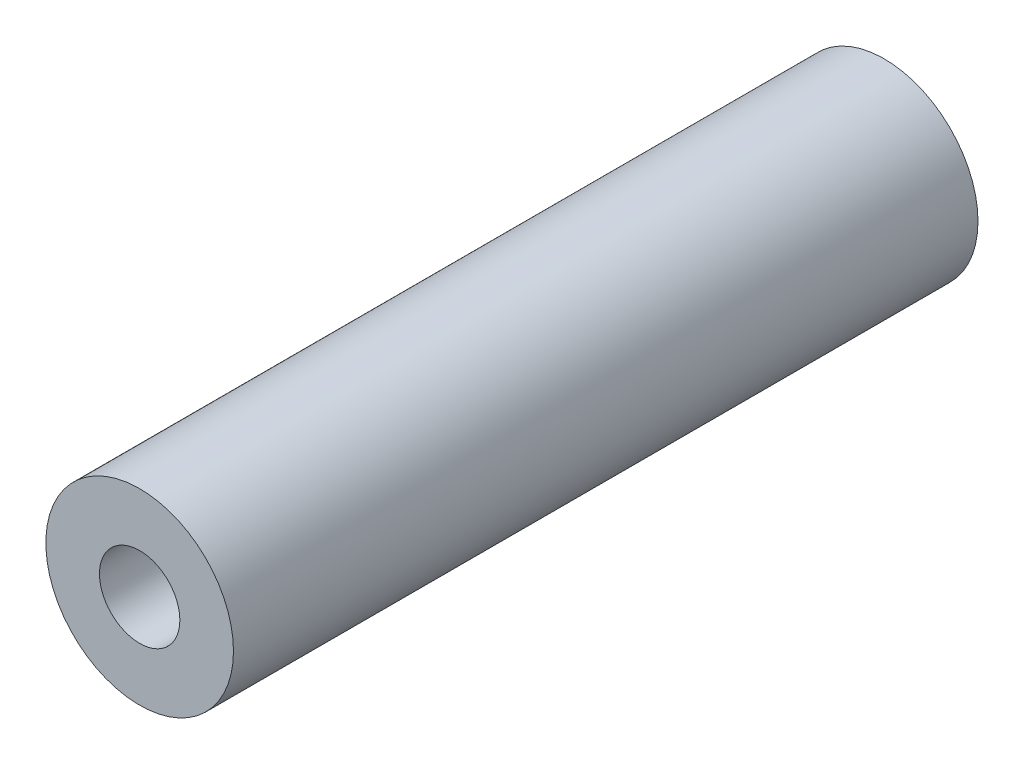
from build123d import *

# Parameters (mm, degrees)
SKETCH7_R           = 3.2004
SKETCH7_R_2         = 1.3716
BOSS_EXTRUDE4_DEPTH = 25.4


with BuildPart() as part:
    # Sketch7 → Boss-Extrude4 (new body)
    with BuildSketch(Plane.XY):
        with Locations((-79.719915494, 6.144314544)):
            Circle(SKETCH7_R)
        with Locations((-79.719915494, 6.144314544)):
            Circle(SKETCH7_R_2, mode=Mode.SUBTRACT)
    extrude(amount=BOSS_EXTRUDE4_DEPTH)


solid = part.part
